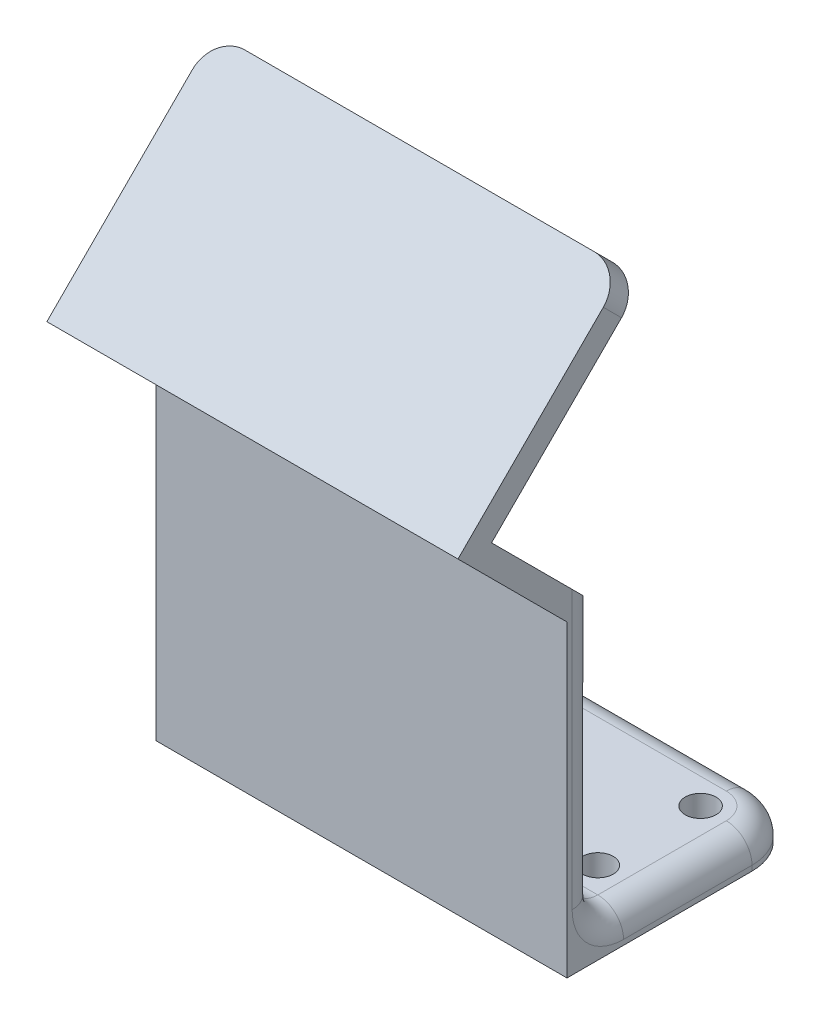
from build123d import *

# Parameters (mm, degrees)
SKETCH1_R           = 1.5
BOSS_EXTRUDE1_DEPTH = 3
SKETCH2_W           = 40
SKETCH2_H           = 30
BOSS_EXTRUDE2_DEPTH = 3
BOSS_EXTRUDE3_DEPTH = 40
CUT_EXTRUDE1_DEPTH  = 3
FILLET2_R           = 2.5


with BuildPart() as part:
    # Sketch1 → Boss-Extrude1 (new body)
    with BuildSketch(Plane(origin=(0, 0, 0), x_dir=(1, 0, 0), z_dir=(0, 1, 0))):
        with BuildLine():
            Line((40, 0), (40, 15))
            ThreePointArc((40, 15), (38.535533906, 18.535533906), (35, 20))
            Line((35, 20), (5, 20))
            ThreePointArc((5, 20), (1.464466094, 18.535533906), (0, 15))
            Line((0, 15), (0, 0))
            Line((0, 0), (40, 0))
        make_face()
        with Locations((5, 15)):
            Circle(SKETCH1_R, mode=Mode.SUBTRACT)
        with Locations((5, 5)):
            Circle(SKETCH1_R, mode=Mode.SUBTRACT)
        with Locations((35, 15)):
            Circle(SKETCH1_R, mode=Mode.SUBTRACT)
        with Locations((35, 5)):
            Circle(SKETCH1_R, mode=Mode.SUBTRACT)
    extrude(amount=BOSS_EXTRUDE1_DEPTH)

    # Sketch2 → Boss-Extrude2 (add)
    with BuildSketch(Plane.XY):
        with Locations((20, 15)):
            Rectangle(SKETCH2_W, SKETCH2_H)
    extrude(amount=BOSS_EXTRUDE2_DEPTH)

    # Sketch3 → Boss-Extrude3 (add)
    with BuildSketch(Plane(origin=(40, 0, 0), x_dir=(0, 0, -1), z_dir=(1, 0, 0))):
        Polygon((-3, 30), (-13.606601718, 40.606601718), (-11.485281374, 42.727922061), (2.656854249, 56.870057685), (4.424621202, 55.102290732), (-10.338834765, 40.338834765), (0, 30), align=None)
    extrude(amount=-BOSS_EXTRUDE3_DEPTH)

    # Sketch4 → Cut-Extrude1 (cut)
    with BuildSketch(Plane(origin=(0, 27.106601718, 27.106601718), x_dir=(1, 0, 0), z_dir=(0, 0.707106781, 0.707106781))):
        with BuildLine():
            Line((3, 42.091883092), (0, 42.091883092))
            Line((0, 42.091883092), (0, 39.091883092))
            ThreePointArc((0, 39.091883092), (0.878679656, 41.213203436), (3, 42.091883092))
        make_face()
        with BuildLine():
            Line((40, 42.091883092), (37, 42.091883092))
            ThreePointArc((37, 42.091883092), (39.121320344, 41.213203436), (40, 39.091883092))
            Line((40, 39.091883092), (40, 42.091883092))
        make_face()
    extrude(amount=-CUT_EXTRUDE1_DEPTH, mode=Mode.SUBTRACT)

    # Fillet2
    fillet2_edges = [part.edges().sort_by_distance(p)[0] for p in [
        (40, 3, -7.5),
        (38.535533906, 3, -18.535533906),
        (20, 3, -20),
        (1.464466094, 3, -18.535533906),
        (0, 16.5, 0),
        (40, 16.5, 0),
        (20, 30, 0),
        (0, 3, -7.5),
        (20, 3, 0),
    ]]
    fillet(fillet2_edges, radius=FILLET2_R)


solid = part.part
